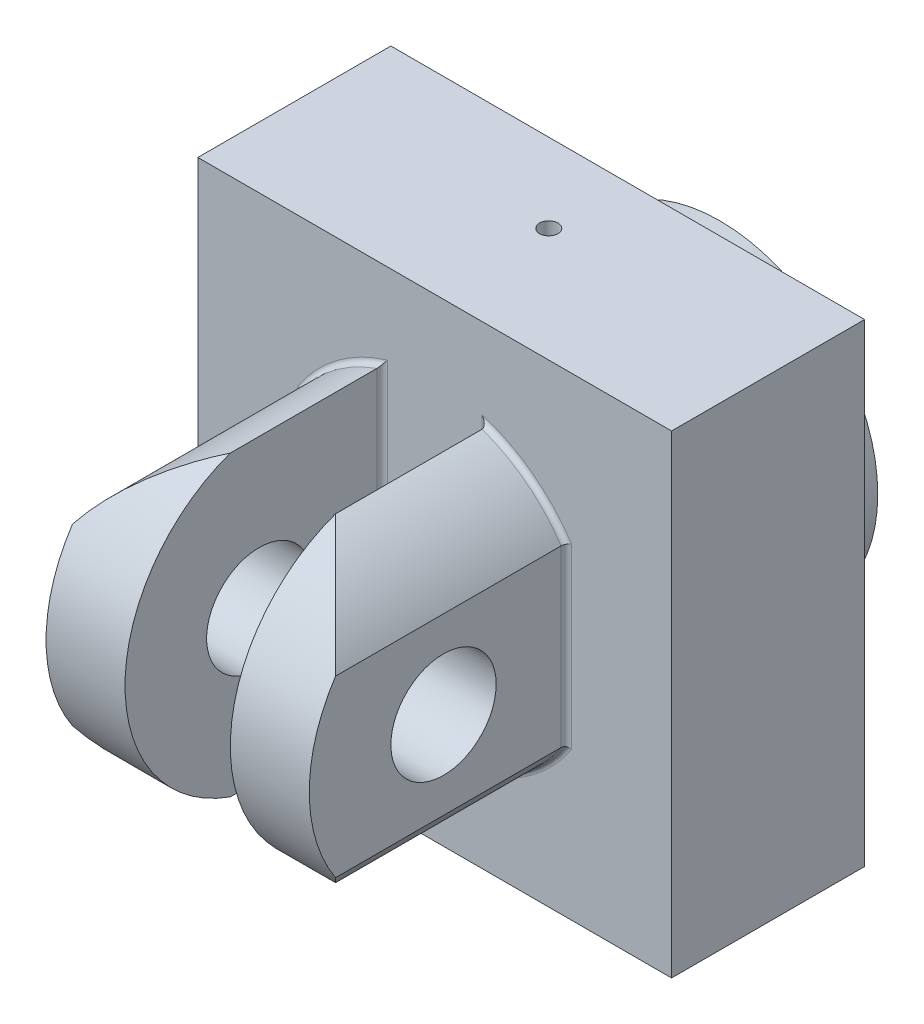
from build123d import *

# Parameters (mm, degrees)
SKETCH2_W               = 90
SKETCH2_H               = 90
BOSS_EXTRUDE1_DEPTH     = 103
CUT_EXTRUDE1_DEPTH      = 122.074357318
CUT_EXTRUDE1_DEPTH_BACK = 122.074357318
SKETCH5_R               = 10
SKETCH6_W               = 80.499612835
SKETCH6_H               = 43.101198191
CUT_EXTRUDE2_DEPTH      = 122.074357403
CUT_EXTRUDE2_DEPTH_BACK = 122.074357403
CUT_EXTRUDE3_START      = 103
CUT_EXTRUDE3_DEPTH      = 103
CUT_EXTRUDE4_REACH      = 145.993
SKETCH10_R              = 1.75
FILLET1_R               = 1


with BuildPart() as part:
    # Sketch2 → Boss-Extrude1 (new body)
    with BuildSketch(Plane.XY):
        Rectangle(SKETCH2_W, SKETCH2_H)
    extrude(amount=BOSS_EXTRUDE1_DEPTH)

    # Sketch4 → Cut-Revolve2 (revolve, cut)
    with BuildSketch(Plane(origin=(0, 0, 0), x_dir=(1, 0, 0), z_dir=(0, 1, 0))):
        Polygon((70, 0), (30, 0), (30, -2.5), (27, -2.5), (27, -6.5), (30, -6.5), (30, -17.5), (70, -17.5), align=None)
        Polygon((24, 0), (0, 0), (0, -39.420654857), (24, -25), align=None)
    revolve(axis=Axis((0, 0, 0), (0, 0, 1)), mode=Mode.SUBTRACT)

    # Sketch5 → Cut-Extrude1 (cut, two sides: drawn at the far end of the back side and taken through both)
    with BuildSketch(Plane(origin=(0, 0, 0), x_dir=(0, 0, -1), z_dir=(1, 0, 0)).offset(-CUT_EXTRUDE1_DEPTH_BACK)):
        with Locations((-77.5, 0)):
            Circle(SKETCH5_R)
    extrude(amount=CUT_EXTRUDE1_DEPTH + CUT_EXTRUDE1_DEPTH_BACK, mode=Mode.SUBTRACT)

    # Sketch6 → Cut-Revolve3 (revolve, cut)
    with BuildSketch(Plane(origin=(0, 0, 0), x_dir=(0, 0, -1), z_dir=(1, 0, 0))):
        with Locations((-94.419607416, 51.550599096)):
            Rectangle(SKETCH6_W, SKETCH6_H)
    revolve(axis=Axis((0, 0, 0), (0, 0, 1)), mode=Mode.SUBTRACT)

    # Sketch7 → Cut-Extrude2 (cut, two sides: drawn at the far end of the back side and taken through both)
    with BuildSketch(Plane(origin=(0, 0, 0), x_dir=(0, 0, -1), z_dir=(1, 0, 0)).offset(-CUT_EXTRUDE2_DEPTH_BACK)):
        with BuildLine():
            ThreePointArc((-77.5, -29.6605799), (-95.748626332, -19.557607216), (-103, 0))
            Line((-103, 0), (-103, -30))
            Line((-103, -30), (-77.5, -30))
            Line((-77.5, -30), (-77.5, -29.6605799))
        make_face()
        with BuildLine():
            Line((-103, 30), (-103, 0))
            ThreePointArc((-103, 0), (-95.748626332, 19.557607216), (-77.5, 29.6605799))
            Line((-77.5, 29.6605799), (-77.5, 30))
            Line((-77.5, 30), (-103, 30))
        make_face()
    extrude(amount=CUT_EXTRUDE2_DEPTH + CUT_EXTRUDE2_DEPTH_BACK, mode=Mode.SUBTRACT)

    # Sketch8 → Cut-Extrude3 (cut)
    with BuildSketch(Plane.XY.offset(54.169800998).offset(CUT_EXTRUDE3_START)):
        with BuildLine():
            ThreePointArc((10, 28.284271247), (0, 30), (-10, 28.284271247))
            Line((-10, 28.284271247), (-10, -28.284271247))
            ThreePointArc((-10, -28.284271247), (0, -30), (10, -28.284271247))
            Line((10, -28.284271247), (10, 28.284271247))
        make_face()
        with BuildLine():
            Line((-25, -16.583123952), (-25, 16.583123952))
            ThreePointArc((-25, 16.583123952), (-30, 0), (-25, -16.583123952))
        make_face()
        with BuildLine():
            ThreePointArc((25, -16.583123952), (30, 0), (25, 16.583123952))
            Line((25, 16.583123952), (25, -16.583123952))
        make_face()
    extrude(amount=-CUT_EXTRUDE3_DEPTH, mode=Mode.SUBTRACT)

    # Sketch10 → Cut-Extrude4 (cut, up to next)
    with BuildSketch(Plane(origin=(0, 45, 0), x_dir=(1, 0, 0), z_dir=(0, 1, 0)), mode=Mode.PRIVATE) as cut_extrude4_sk1:
        with Locations((0, -32.5)):
            Circle(SKETCH10_R)
    cut_extrude4_tool1 = extrude(cut_extrude4_sk1.sketch, amount=-CUT_EXTRUDE4_REACH, mode=Mode.PRIVATE) & part.part
    add(cut_extrude4_tool1.solids().sort_by_distance((0, 45, 32.5))[0], mode=Mode.SUBTRACT)

    # Fillet1
    fillet1_edges = [part.edges().sort_by_distance(p)[0] for p in [
        (-10, 0, 54.169800998),
        (-18.452078799, 23.654191764, 54.169800998),
        (-25, 0, 54.169800998),
        (-18.452078799, -23.654191764, 54.169800998),
        (10, 0, 54.169800998),
        (18.452078799, -23.654191764, 54.169800998),
        (25, 0, 54.169800998),
        (18.452078799, 23.654191764, 54.169800998),
        (-30, 0, 17.5),
    ]]
    fillet(fillet1_edges, radius=FILLET1_R)


solid = part.part
